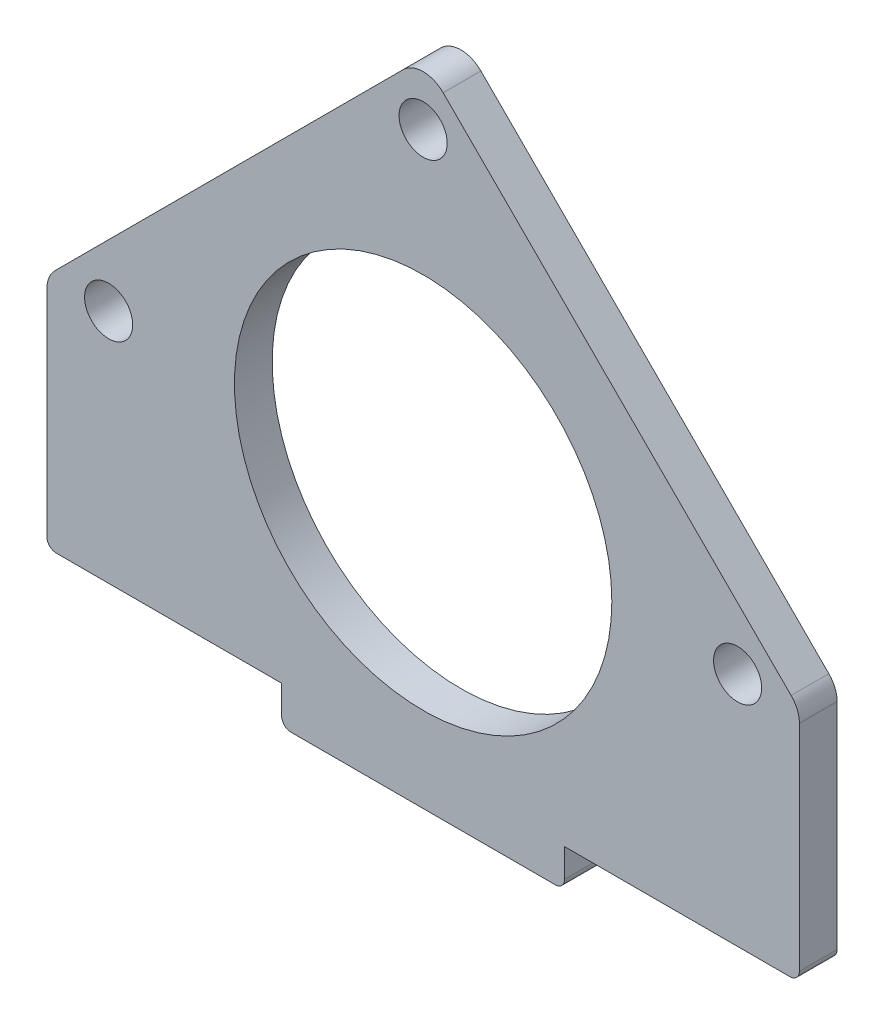
from build123d import *

# Parameters (mm, degrees)
SKETCH_1_R      = 20
SKETCH_1_R_2    = 2.55
EXTRUDE_2_DEPTH = 4
FILLET_1_R      = 3
FILLET_2_R      = 1


with BuildPart() as part:
    # Эскиз1 → Бобышка-Вытянуть2 (new body)
    with BuildSketch(Plane.XY):
        Polygon((-39.880822459, 0), (0, 39.880822459), (39.880822459, 0), (39.880822459, -25), (15, -25), (15, -29), (-15, -29), (-15, -25), (-39.880822459, -25), align=None)
        Circle(SKETCH_1_R, mode=Mode.SUBTRACT)
        with Locations((-33.333013665, 0)):
            Circle(SKETCH_1_R_2, mode=Mode.SUBTRACT)
        with Locations((0, 33.333013665)):
            Circle(SKETCH_1_R_2, mode=Mode.SUBTRACT)
        with Locations((33.333013665, 0)):
            Circle(SKETCH_1_R_2, mode=Mode.SUBTRACT)
    extrude(amount=EXTRUDE_2_DEPTH)

    # Скругление1
    fillet_1_edges = [part.edges().sort_by_distance(p)[0] for p in [
        (-39.880822459, 0, 2),
        (0, 39.880822459, 2),
        (39.880822459, 0, 2),
    ]]
    fillet(fillet_1_edges, radius=FILLET_1_R)

    # Скругление2
    fillet_2_edges = [part.edges().sort_by_distance(p)[0] for p in [
        (39.880822459, -25, 2),
        (15, -29, 2),
        (-15, -29, 2),
        (-39.880822459, -25, 2),
    ]]
    fillet(fillet_2_edges, radius=FILLET_2_R)


solid = part.part
